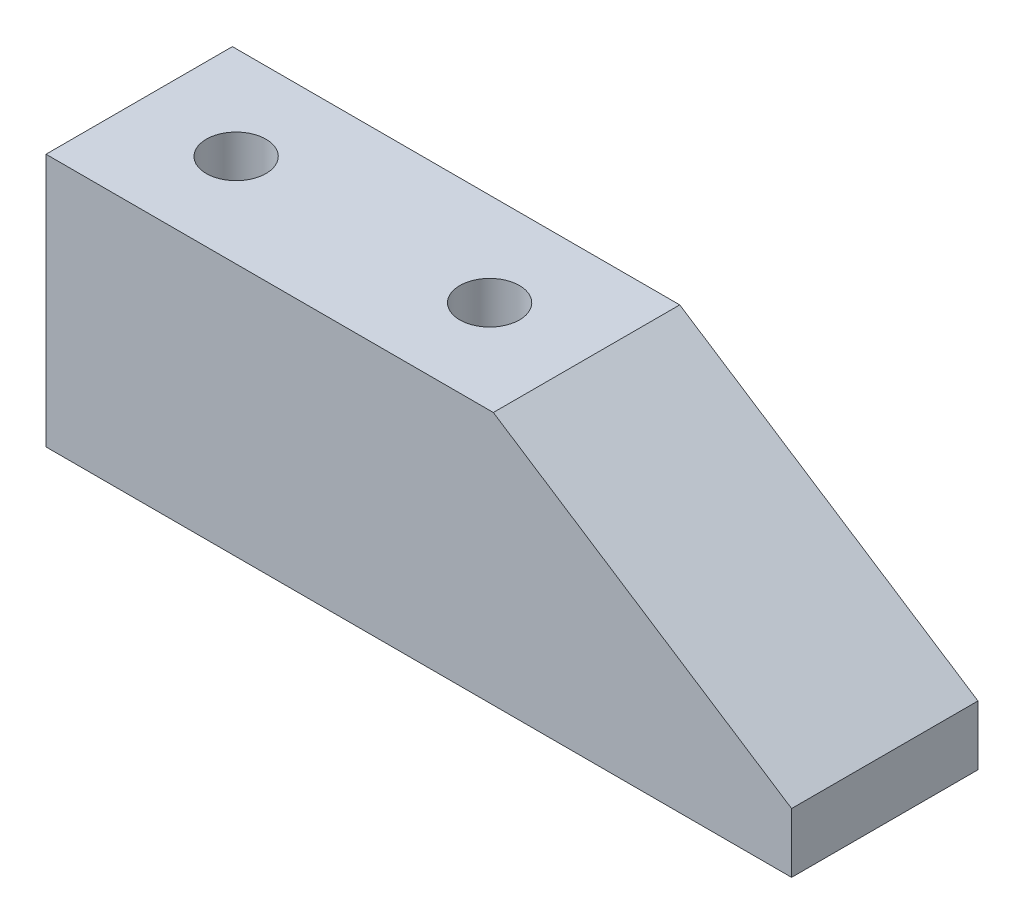
from build123d import *

# Parameters (mm, degrees)
BOSS_EXTRUDE1_DEPTH = 12.5
SKETCH2_R           = 2
CUT_EXTRUDE1_DEPTH  = 8


with BuildPart() as part:
    # Sketch1 → Boss-Extrude1 (new body)
    with BuildSketch(Plane.XY):
        Polygon((0, 0), (0, -17), (50, -17), (50, -13), (30, 0), align=None)
    extrude(amount=BOSS_EXTRUDE1_DEPTH)

    # Sketch2 → Cut-Extrude1 (cut)
    with BuildSketch(Plane(origin=(0, 0, 0), x_dir=(1, 0, 0), z_dir=(0, 1, 0))):
        with Locations((6.5, -6.25)):
            Circle(SKETCH2_R)
        with Locations((23.5, -6.25)):
            Circle(SKETCH2_R)
    extrude(amount=-CUT_EXTRUDE1_DEPTH, mode=Mode.SUBTRACT)


solid = part.part
